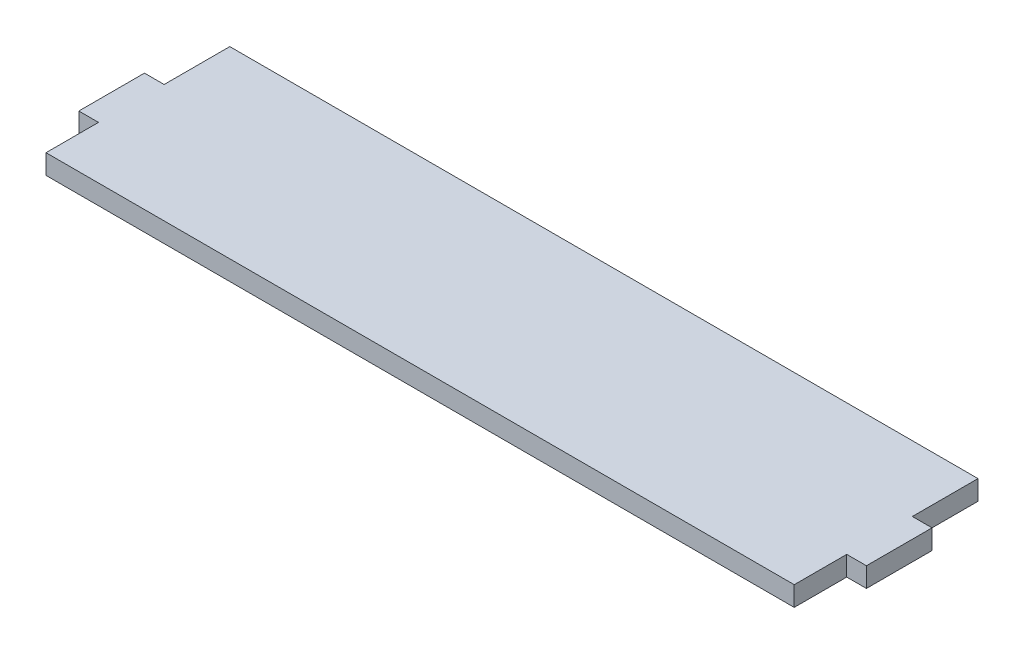
from build123d import *

# Parameters (mm, degrees)
SALIENTE_EXTRUIR1_DEPTH = 3


with BuildPart() as part:
    # Croquis1 → Saliente-Extruir1 (new body)
    with BuildSketch(Plane(origin=(0, 0, 0), x_dir=(1, 0, 0), z_dir=(0, 1, 0))):
        Polygon((-57, 4), (-60, 4), (-60, -6), (-57, -6), (-57, -14), (57, -14), (57, -6), (60, -6), (60, 4), (57, 4), (57, 14), (-57, 14), align=None)
    extrude(amount=SALIENTE_EXTRUIR1_DEPTH)


solid = part.part
